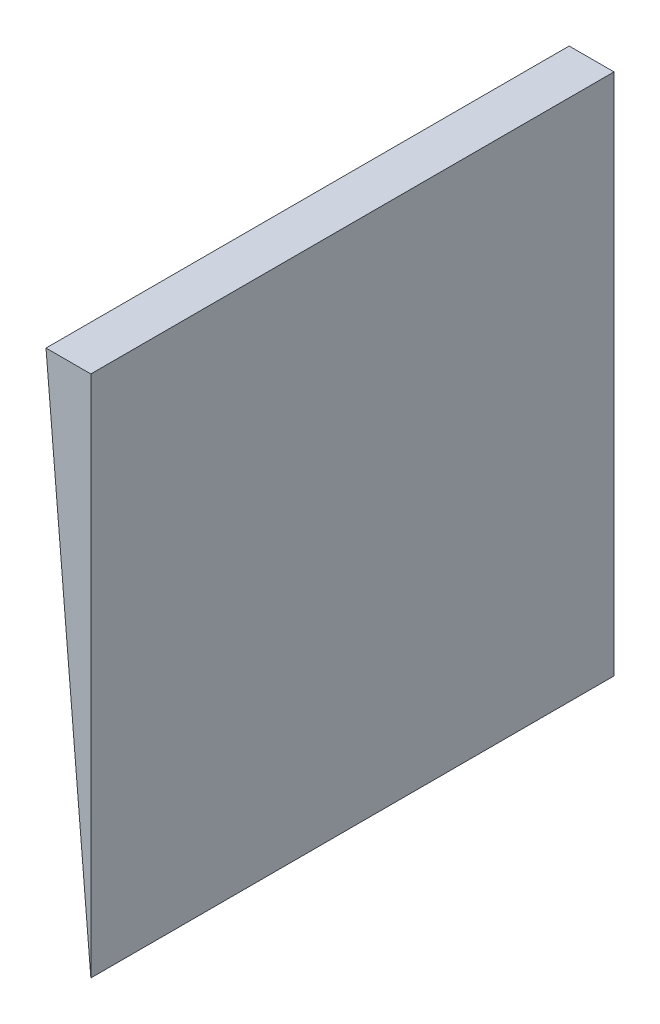
from build123d import *

# Parameters (mm, degrees)
BOSS_EXTRUDE1_DEPTH = 35


with BuildPart() as part:
    # Sketch1 → Boss-Extrude1 (new body)
    with BuildSketch(Plane.XY):
        Polygon((0, 0), (0, 35), (-3, 35), align=None)
    extrude(amount=BOSS_EXTRUDE1_DEPTH)


solid = part.part
